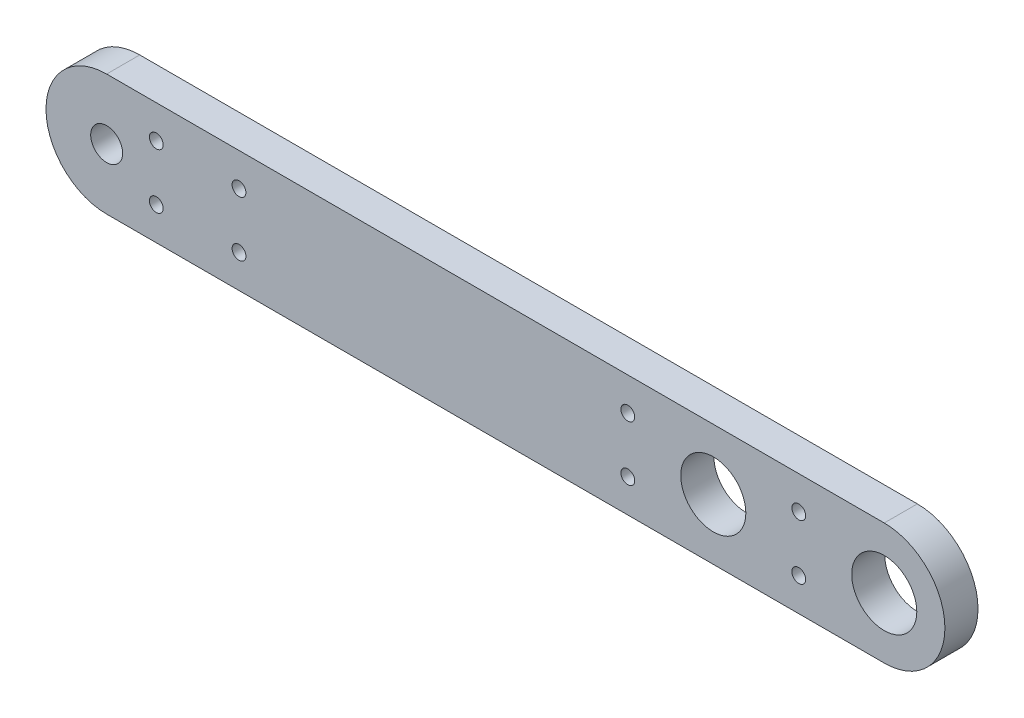
from build123d import *

# Parameters (mm, degrees)
SKETCH1_R           = 1.45
SKETCH1_R_2         = 2.95
BOSS_EXTRUDE1_DEPTH = 3
TROU_TARAUD_M1_61_D = 1.25


with BuildPart() as part:
    # Sketch1 → Boss-Extrude1 (new body)
    with BuildSketch(Plane.XY):
        with BuildLine():
            Line((15.5, 5.5), (-55, 5.5))
            ThreePointArc((-55, 5.5), (-60.5, 0), (-55, -5.5))
            Line((-55, -5.5), (15.5, -5.5))
            ThreePointArc((15.5, -5.5), (21, 0), (15.5, 5.5))
        make_face()
        with Locations((-55, 0)):
            Circle(SKETCH1_R, mode=Mode.SUBTRACT)
        Circle(SKETCH1_R_2, mode=Mode.SUBTRACT)
        with Locations((15.5, 0)):
            Circle(SKETCH1_R_2, mode=Mode.SUBTRACT)
    extrude(amount=BOSS_EXTRUDE1_DEPTH)

    # Trou taraudé M1.61 (through all)
    with Locations(Plane.XY.offset(3)):
        with Locations((7.75, 2.5), (-7.75, 2.5), (-50.5, 2.5), (-43, 2.5)):
            trou_taraud_m1_61 = Hole(TROU_TARAUD_M1_61_D / 2)

    # Mirror1: Trou taraudé M1.61 across plane
    add(trou_taraud_m1_61.mirror(Plane.ZX), mode=Mode.SUBTRACT)


solid = part.part
